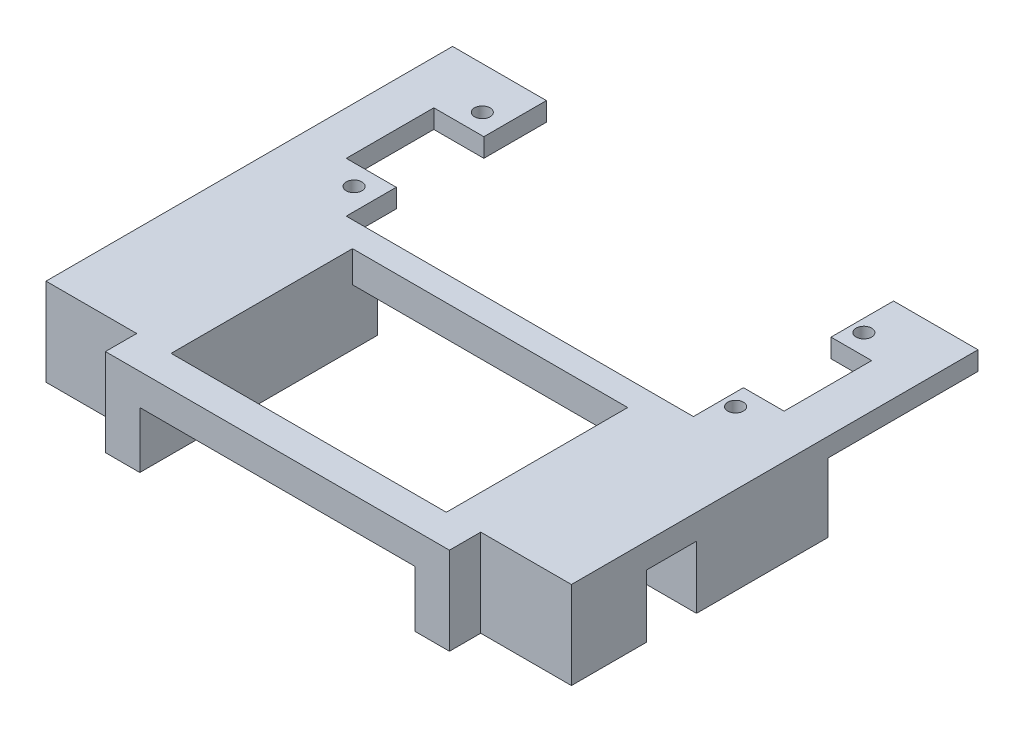
from build123d import *

# Parameters (mm, degrees)
SKETCH1_W           = 70
SKETCH1_H           = 30
SKETCH1_W_2         = 55
SKETCH1_H_2         = 5
BOSS_EXTRUDE1_DEPTH = 5
BOSS_EXTRUDE2_DEPTH = 9
CUT_EXTRUDE1_DEPTH  = 2
BOSS_EXTRUDE3_DEPTH = 3
SKETCH7_W           = 54
SKETCH7_H           = 2
SKETCH7_W_2         = 1.5
SKETCH7_H_2         = 8
CUT_EXTRUDE4_DEPTH  = 10
SKETCH8_W           = 10
SKETCH8_H           = 8
CUT_EXTRUDE5_DEPTH  = 10


with BuildPart() as part:
    # Sketch1 → Boss-Extrude1 (new body)
    with BuildSketch(Plane(origin=(0, 0, 0), x_dir=(1, 0, 0), z_dir=(0, 1, 0))):
        Polygon((-5.25, -11), (-29.5, -11), (-42, -11), (-42, -76), (-27.5, -76), (-22, -76), (-22, -47), (22, -47), (22, -76), (27.5, -76), (42, -76), (42, -11), (29.5, -11), (5.25, -11), align=None)
        with Locations((0, -28)):
            Rectangle(SKETCH1_W, SKETCH1_H, mode=Mode.SUBTRACT)
        Polygon((-5.25, -11), (-29.5, -11), (-42, -11), (-42, -76), (-27.5, -76), (-22, -76), (-22, -47), (22, -47), (22, -76), (27.5, -76), (42, -76), (42, -11), (29.5, -11), (5.25, -11), align=None)
        with Locations((0, -28)):
            Rectangle(SKETCH1_W, SKETCH1_H, mode=Mode.SUBTRACT)
        Polygon((-5.25, -11), (-29.5, -11), (-42, -11), (-42, -76), (-27.5, -76), (-22, -76), (-22, -47), (22, -47), (22, -76), (27.5, -76), (42, -76), (42, -11), (29.5, -11), (5.25, -11), align=None)
        with Locations((0, -28)):
            Rectangle(SKETCH1_W, SKETCH1_H, mode=Mode.SUBTRACT)
        with Locations((0, -78.5)):
            Rectangle(SKETCH1_W_2, SKETCH1_H_2)
    extrude(amount=BOSS_EXTRUDE1_DEPTH)

    # Sketch2 → Boss-Extrude2 (add)
    with BuildSketch(Plane.XZ):
        Polygon((-27.5, 76), (-42, 76), (-42, 35), (-35, 35), (-35, 43), (-22, 43), (-22, 81), (-27.5, 81), align=None)
        Polygon((22, 81), (22, 43), (35, 43), (35, 35), (42, 35), (42, 76), (27.5, 76), (27.5, 81), align=None)
    extrude(amount=BOSS_EXTRUDE2_DEPTH)

    # Sketch3 → Cut-Extrude1 (cut)
    with BuildSketch(Plane.XZ):
        Polygon((-42, 35), (-42, 11), (42, 11), (42, 35), (35, 35), (35, 13), (-35, 13), (-35, 35), align=None)
    extrude(amount=-CUT_EXTRUDE1_DEPTH, mode=Mode.SUBTRACT)

    # Sketch6 → Boss-Extrude3 (add)
    with BuildSketch(Plane(origin=(0, 5, 0), x_dir=(1, 0, 0), z_dir=(0, 1, 0))):
        with BuildLine():
            ThreePointArc((-30.5, -19), (-31.383883476, -16.866116524), (-29.25, -17.75))
            Line((-29.25, -17.75), (-27, -17.75))
            Line((-27, -17.75), (-27, -13))
            Line((-27, -13), (-35, -13))
            Line((-35, -13), (-35, -21))
            Line((-35, -21), (-30.5, -21))
            Line((-30.5, -21), (-30.5, -19))
        make_face()
        with BuildLine():
            Line((-27, -17.75), (-29.25, -17.75))
            ThreePointArc((-29.25, -17.75), (-29.616116524, -18.633883476), (-30.5, -19))
            Line((-30.5, -19), (-30.5, -21))
            Line((-30.5, -21), (-27, -21))
            Line((-27, -21), (-27, -17.75))
        make_face()
        with BuildLine():
            Line((-30.5, -37), (-30.5, -35))
            Line((-30.5, -35), (-35, -35))
            Line((-35, -35), (-35, -43))
            Line((-35, -43), (-27, -43))
            Line((-27, -43), (-27, -38.25))
            Line((-27, -38.25), (-29.25, -38.25))
            ThreePointArc((-29.25, -38.25), (-31.383883476, -39.133883476), (-30.5, -37))
        make_face()
        with BuildLine():
            Line((-27, -35), (-30.5, -35))
            Line((-30.5, -35), (-30.5, -37))
            ThreePointArc((-30.5, -37), (-29.616116524, -37.366116524), (-29.25, -38.25))
            Line((-29.25, -38.25), (-27, -38.25))
            Line((-27, -38.25), (-27, -35))
        make_face()
        with BuildLine():
            Line((35, -35), (30.5, -35))
            Line((30.5, -35), (30.5, -37))
            ThreePointArc((30.5, -37), (31.383883476, -37.366116524), (31.75, -38.25))
            ThreePointArc((31.75, -38.25), (30.5, -39.5), (29.25, -38.25))
            Line((29.25, -38.25), (27, -38.25))
            Line((27, -38.25), (27, -43))
            Line((27, -43), (35, -43))
            Line((35, -43), (35, -35))
        make_face()
        with BuildLine():
            Line((30.5, -37), (30.5, -35))
            Line((30.5, -35), (27, -35))
            Line((27, -35), (27, -38.25))
            Line((27, -38.25), (29.25, -38.25))
            ThreePointArc((29.25, -38.25), (29.616116524, -37.366116524), (30.5, -37))
        make_face()
        with BuildLine():
            Line((27, -13), (27, -17.75))
            Line((27, -17.75), (29.25, -17.75))
            ThreePointArc((29.25, -17.75), (30.5, -16.5), (31.75, -17.75))
            ThreePointArc((31.75, -17.75), (31.383883476, -18.633883476), (30.5, -19))
            Line((30.5, -19), (30.5, -21))
            Line((30.5, -21), (35, -21))
            Line((35, -21), (35, -13))
            Line((35, -13), (27, -13))
        make_face()
        with BuildLine():
            Line((29.25, -17.75), (27, -17.75))
            Line((27, -17.75), (27, -21))
            Line((27, -21), (30.5, -21))
            Line((30.5, -21), (30.5, -19))
            ThreePointArc((30.5, -19), (29.616116524, -18.633883476), (29.25, -17.75))
        make_face()
    extrude(amount=-BOSS_EXTRUDE3_DEPTH)

    # Sketch7 → Cut-Extrude4 (cut)
    with BuildSketch(Plane(origin=(0, 5, 0), x_dir=(1, 0, 0), z_dir=(0, 1, 0))):
        Polygon((27, -11), (27, -13), (27, -21), (28.5, -21), (28.5, -11), align=None)
        with Locations((0, -12)):
            Rectangle(SKETCH7_W, SKETCH7_H)
        with Locations((27.75, -39)):
            Rectangle(SKETCH7_W_2, SKETCH7_H_2)
    extrude(amount=-CUT_EXTRUDE4_DEPTH, mode=Mode.SUBTRACT)

    # Sketch8 → Cut-Extrude5 (cut)
    with BuildSketch(Plane.XZ.offset(9)):
        with Locations((-37, 60)):
            Rectangle(SKETCH8_W, SKETCH8_H)
        with Locations((37, 60)):
            Rectangle(SKETCH8_W, SKETCH8_H)
    extrude(amount=-CUT_EXTRUDE5_DEPTH, mode=Mode.SUBTRACT)


solid = part.part
